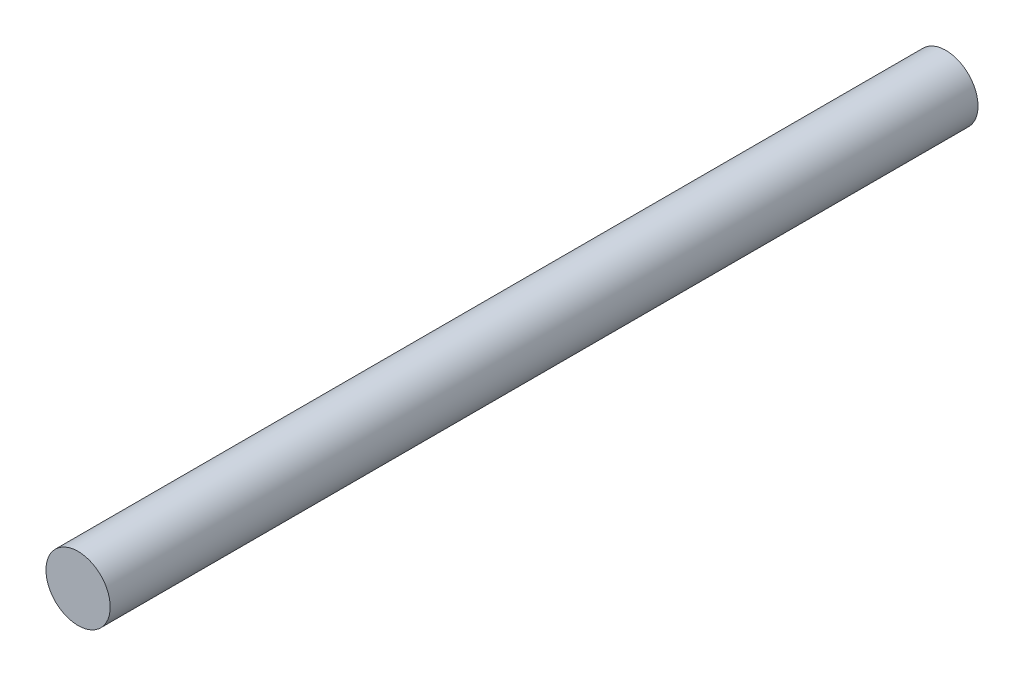
from build123d import *

# Parameters (mm, degrees)
SKETCH1_R           = 2
BOSS_EXTRUDE1_DEPTH = 54


with BuildPart() as part:
    # Sketch1 → Boss-Extrude1 (new body)
    with BuildSketch(Plane.XY):
        Circle(SKETCH1_R)
    extrude(amount=BOSS_EXTRUDE1_DEPTH)


solid = part.part
